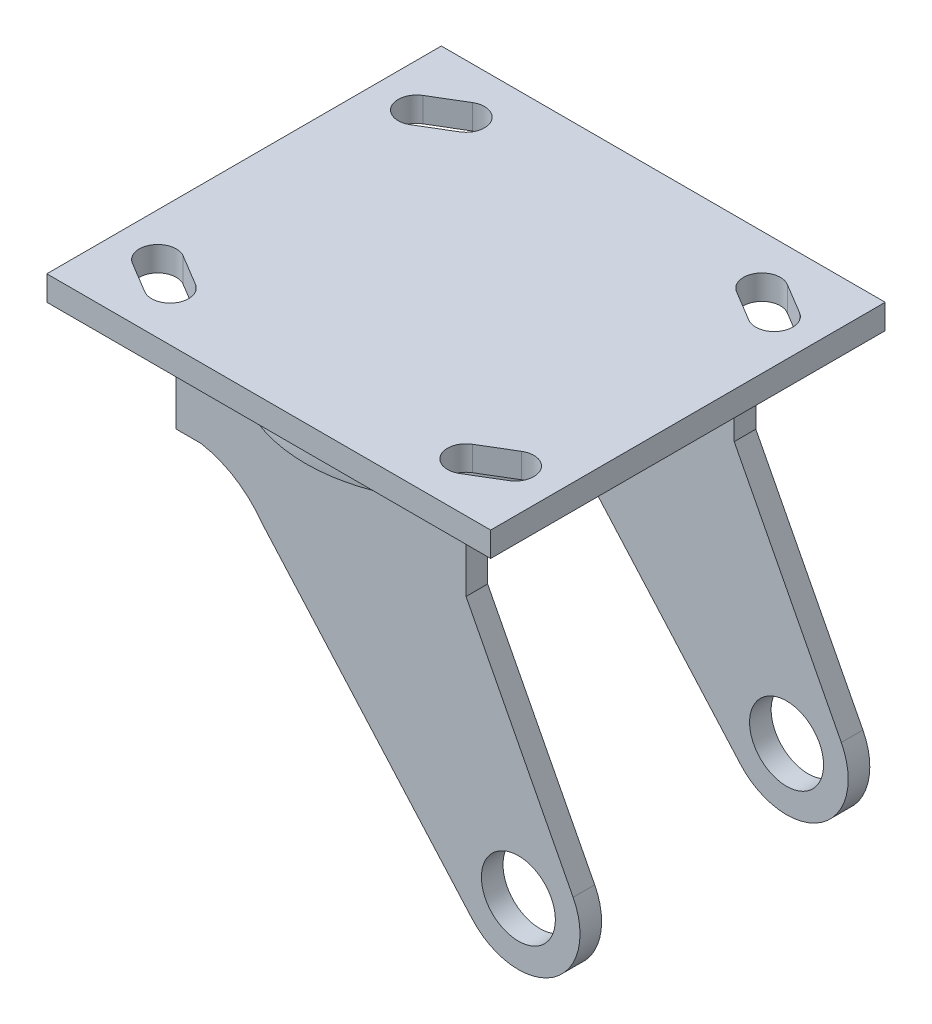
from build123d import *

# Parameters (mm, degrees)
ESBO_O1_W                  = 114.3
ESBO_O1_H                  = 101.6
RESSALTO_EXTRUS_O1_DEPTH   = 6.35
ESBO_O3_W                  = 74.6252
ESBO_O3_H                  = 89.6874
RESSALTO_EXTRUS_O2_DEPTH   = 129.54
CORTE_EXTRUS_O1_DEPTH      = 129.54
CORTE_EXTRUS_O2_DEPTH      = 17.78
CORTE_EXTRUS_O3_DEPTH      = 17.78
ESBO_O7_R                  = 9.525
CORTE_EXTRUS_O4_DEPTH      = 5.5626
ESBO_O8_R                  = 9.525
CORTE_EXTRUS_O5_DEPTH      = 5.5626
CORTE_EXTRUS_O6_DEPTH      = 31.75
CORTE_EXTRUS_O6_DEPTH_BACK = 31.75


with BuildPart() as part:
    # Esboço1 → Ressalto-extrusão1 (new body)
    with BuildSketch(Plane(origin=(0, 0, 0), x_dir=(1, 0, 0), z_dir=(0, 1, 0))):
        with Locations((57.15, 0)):
            Rectangle(ESBO_O1_W, ESBO_O1_H)
        with BuildLine():
            Line((92.799713965, 34.016189941), (100.737213965, 29.253689941))
            ThreePointArc((100.737213965, 29.253689941), (107.271310059, 30.887213965), (105.637786035, 37.421310059))
            Line((105.637786035, 37.421310059), (97.700286035, 42.183810059))
            ThreePointArc((97.700286035, 42.183810059), (91.166189941, 40.550286035), (92.799713965, 34.016189941))
        make_face(mode=Mode.SUBTRACT)
        with BuildLine():
            Line((97.700286035, -42.183810059), (105.637786035, -37.421310059))
            ThreePointArc((105.637786035, -37.421310059), (107.271310059, -30.887213965), (100.737213965, -29.253689941))
            Line((100.737213965, -29.253689941), (92.799713965, -34.016189941))
            ThreePointArc((92.799713965, -34.016189941), (91.166189941, -40.550286035), (97.700286035, -42.183810059))
        make_face(mode=Mode.SUBTRACT)
        with BuildLine():
            Line((13.562786035, 29.253689941), (21.500286035, 34.016189941))
            ThreePointArc((21.500286035, 34.016189941), (23.133810059, 40.550286035), (16.599713965, 42.183810059))
            Line((16.599713965, 42.183810059), (8.662213965, 37.421310059))
            ThreePointArc((8.662213965, 37.421310059), (7.028689941, 30.887213965), (13.562786035, 29.253689941))
        make_face(mode=Mode.SUBTRACT)
        with BuildLine():
            Line((8.662213965, -37.421310059), (16.599713965, -42.183810059))
            ThreePointArc((16.599713965, -42.183810059), (23.133810059, -40.550286035), (21.500286035, -34.016189941))
            Line((21.500286035, -34.016189941), (13.562786035, -29.253689941))
            ThreePointArc((13.562786035, -29.253689941), (7.028689941, -30.887213965), (8.662213965, -37.421310059))
        make_face(mode=Mode.SUBTRACT)
    extrude(amount=RESSALTO_EXTRUS_O1_DEPTH)

    # Esboço2 → Revolução1 (revolve)
    with BuildSketch(Plane.XY):
        with BuildLine():
            Line((57.15, 0), (96.212075536, 0))
            ThreePointArc((96.212075536, 0), (97.965508733, -5.977876228), (98.425, -12.190637285))
            Line((98.425, -12.190637285), (57.15, -12.190637285))
            Line((57.15, -12.190637285), (57.15, 0))
        make_face()
    revolve(axis=Axis((57.15, -12.190637285, 0), (0, 1, 0)))

    # Esboço3 → Ressalto-extrusão2 (add)
    with BuildSketch(Plane(origin=(0, 0, 0), x_dir=(0, 0, -1), z_dir=(1, 0, 0))):
        with Locations((0, -56.7563)):
            Rectangle(ESBO_O3_W, ESBO_O3_H)
    extrude(amount=RESSALTO_EXTRUS_O2_DEPTH)

    # Esboço4 → Corte-extrusão1 (cut)
    with BuildSketch(Plane(origin=(0, 0, 0), x_dir=(0, 0, -1), z_dir=(1, 0, 0))):
        with BuildLine():
            Line((-31.75, -27.323981416), (-31.75, -101.6))
            Line((-31.75, -101.6), (31.75, -101.6))
            Line((31.75, -101.6), (31.75, -27.323981416))
            ThreePointArc((31.75, -27.323981416), (28.496991957, -17.652408672), (20.060406327, -11.9126))
            Line((20.060406327, -11.9126), (-20.060406327, -11.9126))
            ThreePointArc((-20.060406327, -11.9126), (-28.496991957, -17.652408672), (-31.75, -27.323981416))
        make_face()
    extrude(amount=CORTE_EXTRUS_O1_DEPTH, mode=Mode.SUBTRACT)

    # Esboço5 → Corte-extrusão2 (cut)
    with BuildSketch(Plane.XY.offset(37.3126)):
        with BuildLine():
            Line((0, -11.9126), (0, -113.5126))
            Line((0, -113.5126), (129.54, -113.5126))
            Line((129.54, -113.5126), (129.54, -11.9126))
            Line((129.54, -11.9126), (94.472692749, -11.9126))
            Line((94.472692749, -11.9126), (94.472692749, -25.121962715))
            Line((94.472692749, -25.121962715), (122.05004704, -78.430872329))
            ThreePointArc((122.05004704, -78.430872329), (116.924107122, -98.820076417), (96.059025593, -96.242621055))
            Line((96.059025593, -96.242621055), (41.979486254, -35.10156883))
            ThreePointArc((41.979486254, -35.10156883), (35.071399527, -28.539398345), (26.177307251, -25.121962715))
            Line((26.177307251, -25.121962715), (19.827307251, -25.121962715))
            Line((19.827307251, -25.121962715), (19.827307251, -11.9126))
            Line((19.827307251, -11.9126), (0, -11.9126))
        make_face()
    extrude(amount=-CORTE_EXTRUS_O2_DEPTH, mode=Mode.SUBTRACT)

    # Esboço6 → Corte-extrusão3 (cut)
    with BuildSketch(Plane.XY.offset(-37.3126)):
        with BuildLine():
            Line((0, -11.9126), (0, -113.5126))
            Line((0, -113.5126), (129.54, -113.5126))
            Line((129.54, -113.5126), (129.54, -11.9126))
            Line((129.54, -11.9126), (94.472692749, -11.9126))
            Line((94.472692749, -11.9126), (94.472692749, -25.121962715))
            Line((94.472692749, -25.121962715), (122.05004704, -78.430872329))
            ThreePointArc((122.05004704, -78.430872329), (116.924107122, -98.820076417), (96.059025593, -96.242621055))
            Line((96.059025593, -96.242621055), (41.979486254, -35.10156883))
            ThreePointArc((41.979486254, -35.10156883), (35.071399527, -28.539398345), (26.177307251, -25.121962715))
            Line((26.177307251, -25.121962715), (19.827307251, -25.121962715))
            Line((19.827307251, -25.121962715), (19.827307251, -11.9126))
            Line((19.827307251, -11.9126), (0, -11.9126))
        make_face()
    extrude(amount=CORTE_EXTRUS_O3_DEPTH, mode=Mode.SUBTRACT)

    # Esboço7 → Corte-extrusão4 (cut)
    with BuildSketch(Plane.XY.offset(37.3126)):
        with Locations((107.95, -85.725)):
            Circle(ESBO_O7_R)
    extrude(amount=-CORTE_EXTRUS_O4_DEPTH, mode=Mode.SUBTRACT)

    # Esboço8 → Corte-extrusão5 (cut)
    with BuildSketch(Plane.XY.offset(-37.3126)):
        with Locations((107.95, -85.725)):
            Circle(ESBO_O8_R)
    extrude(amount=CORTE_EXTRUS_O5_DEPTH, mode=Mode.SUBTRACT)

    # Esboço9 → Corte-extrusão6 (cut, two sides)
    with BuildSketch(Plane.XY) as corte_extrus_o6_sk:
        with BuildLine():
            Line((79.375, -65.0875), (150.000604013, -65.0875))
            ThreePointArc((150.000604013, -65.0875), (166.323156329, -59.148596729), (175.012790586, -44.109097315))
            Line((175.012790586, -44.109097315), (110.495145555, -17.4625))
            Line((110.495145555, -17.4625), (79.375, -17.4625))
            ThreePointArc((79.375, -17.4625), (72.639807909, -20.252307909), (69.85, -26.9875))
            Line((69.85, -26.9875), (69.85, -55.5625))
            ThreePointArc((69.85, -55.5625), (72.639807909, -62.297692091), (79.375, -65.0875))
        make_face()
    extrude(amount=CORTE_EXTRUS_O6_DEPTH, mode=Mode.SUBTRACT)
    extrude(corte_extrus_o6_sk.sketch, amount=-CORTE_EXTRUS_O6_DEPTH_BACK, mode=Mode.SUBTRACT)


solid = part.part
